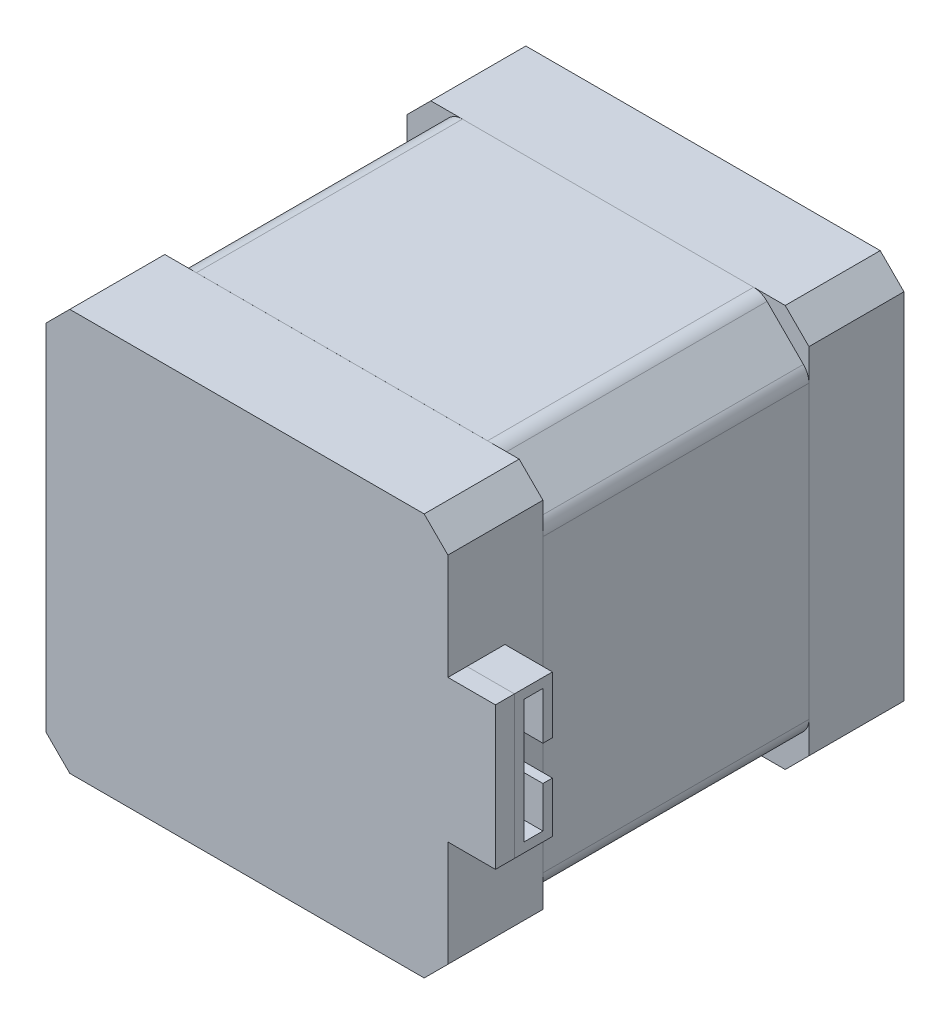
from build123d import *

# Parameters (mm, degrees)
SKETCH1_W           = 42.3
SKETCH1_H           = 42.3
BOSS_EXTRUDE2_DEPTH = 10
SKETCH2_W           = 42.3
SKETCH2_H           = 42.3
BOSS_EXTRUDE3_DEPTH = 28
CHAMFER1_SIZE       = 5
FILLET1_R           = 2
CHAMFER2_SIZE       = 2.5
SKETCH4_W           = 42.3
SKETCH4_H           = 42.3
BOSS_EXTRUDE4_DEPTH = 10
CHAMFER3_SIZE       = 2.5
SKETCH5_R           = 11
BOSS_EXTRUDE5_DEPTH = 2
SKETCH6_R           = 4
CUT_EXTRUDE1_DEPTH  = 2
SKETCH7_R           = 2.5
CUT_EXTRUDE2_DEPTH  = 1
SKETCH11_R          = 1.5
CUT_EXTRUDE3_DEPTH  = 2.5
SKETCH12_W          = 2
SKETCH12_H          = 15
BOSS_EXTRUDE6_DEPTH = 5
BOSS_EXTRUDE7_DEPTH = 5


with BuildPart() as part:
    # Sketch1 → Boss-Extrude2 (new body)
    with BuildSketch(Plane.XY):
        with Locations((-0.247770908, 2.923963134)):
            Rectangle(SKETCH1_W, SKETCH1_H)
    extrude(amount=BOSS_EXTRUDE2_DEPTH)

    # Chamfer2
    chamfer2_edges = [part.edges().sort_by_distance(p)[0] for p in [
        (-21.397770908, 24.073963134, 5),
        (20.902229092, 24.073963134, 5),
        (20.902229092, -18.226036866, 5),
        (-21.397770908, -18.226036866, 5),
    ]]
    chamfer(chamfer2_edges, length=CHAMFER2_SIZE)

    # Sketch5 → Boss-Extrude5 (add)
    with BuildSketch(Plane(origin=(0, 0, 0), x_dir=(-1, 0, 0), z_dir=(0, 0, -1))):
        with Locations((0.247770908, 2.923963134)):
            Circle(SKETCH5_R)
    extrude(amount=BOSS_EXTRUDE5_DEPTH)

    # Sketch6 → Cut-Extrude1 (cut)
    with BuildSketch(Plane(origin=(0, 0, -2), x_dir=(-1, 0, 0), z_dir=(0, 0, -1))):
        with Locations((0.247770908, 2.923963134)):
            Circle(SKETCH6_R)
    extrude(amount=-CUT_EXTRUDE1_DEPTH, mode=Mode.SUBTRACT)

    # Sketch7 → Cut-Extrude2 (cut)
    with BuildSketch(Plane(origin=(0, 0, 0), x_dir=(-1, 0, 0), z_dir=(0, 0, -1))):
        with Locations((0.247770908, 2.923963134)):
            Circle(SKETCH7_R)
    extrude(amount=-CUT_EXTRUDE2_DEPTH, mode=Mode.SUBTRACT)

    # Sketch11 → Cut-Extrude3 (cut)
    with BuildSketch(Plane(origin=(0, 0, 0), x_dir=(-1, 0, 0), z_dir=(0, 0, -1))):
        with Locations((-15.252229092, 18.423963134)):
            Circle(SKETCH11_R)
        with Locations((15.747770908, 18.423963134)):
            Circle(SKETCH11_R)
        with Locations((15.747770908, -12.576036866)):
            Circle(SKETCH11_R)
        with Locations((-15.252229092, -12.576036866)):
            Circle(SKETCH11_R)
    extrude(amount=-CUT_EXTRUDE3_DEPTH, mode=Mode.SUBTRACT)


with BuildPart() as body_2:
    # Sketch2 → Boss-Extrude3 (new body)
    with BuildSketch(Plane.XY.offset(10)):
        with Locations((-0.247770908, 2.923963134)):
            Rectangle(SKETCH2_W, SKETCH2_H)
    extrude(amount=BOSS_EXTRUDE3_DEPTH)

    # Chamfer1
    chamfer1_edges = [body_2.edges().sort_by_distance(p)[0] for p in [
        (-21.397770908, 24.073963134, 24),
        (20.902229092, 24.073963134, 24),
        (20.902229092, -18.226036866, 24),
        (-21.397770908, -18.226036866, 24),
    ]]
    chamfer(chamfer1_edges, length=CHAMFER1_SIZE)

    # Fillet1
    fillet1_edges = [body_2.edges().sort_by_distance(p)[0] for p in [
        (20.902229092, 19.073963134, 24),
        (20.902229092, -13.226036866, 24),
        (-16.397770908, -18.226036866, 24),
        (15.902229092, -18.226036866, 24),
        (-21.397770908, 19.073963134, 24),
        (-21.397770908, -13.226036866, 24),
        (15.902229092, 24.073963134, 24),
        (-16.397770908, 24.073963134, 24),
    ]]
    fillet(fillet1_edges, radius=FILLET1_R)


with BuildPart() as body_3:
    # Sketch4 → Boss-Extrude4 (new body)
    with BuildSketch(Plane.XY.offset(38)):
        with Locations((-0.247770908, 2.921958388)):
            Rectangle(SKETCH4_W, SKETCH4_H)
    extrude(amount=BOSS_EXTRUDE4_DEPTH)

    # Chamfer3
    chamfer3_edges = [body_3.edges().sort_by_distance(p)[0] for p in [
        (-21.397770908, 24.071958388, 43),
        (20.902229092, 24.071958388, 43),
        (20.902229092, -18.228041612, 43),
        (-21.397770908, -18.228041612, 43),
    ]]
    chamfer(chamfer3_edges, length=CHAMFER3_SIZE)

    # Sketch12 → Boss-Extrude6 (add)
    with BuildSketch(Plane(origin=(20.902229092, 0, 0), x_dir=(0, 0, -1), z_dir=(1, 0, 0))):
        with Locations((-47, 2.921958388)):
            Rectangle(SKETCH12_W, SKETCH12_H)
    extrude(amount=BOSS_EXTRUDE6_DEPTH)


with BuildPart() as body_4:
    # Sketch13 → Boss-Extrude7 (new body)
    with BuildSketch(Plane(origin=(20.902229092, 0, 0), x_dir=(0, 0, -1), z_dir=(1, 0, 0))):
        Polygon((-46, 10.421958388), (-42, 10.421958388), (-42, 4.421958388), (-43, 4.421958388), (-43, 9.421958388), (-45, 9.421958388), (-45, -3.578041612), (-43, -3.578041612), (-43, 0.749984504), (-42, 0.749984504), (-42, -4.578041612), (-46, -4.578041612), align=None)
    extrude(amount=BOSS_EXTRUDE7_DEPTH)


solid = Compound([part.part, body_2.part, body_3.part, body_4.part])
